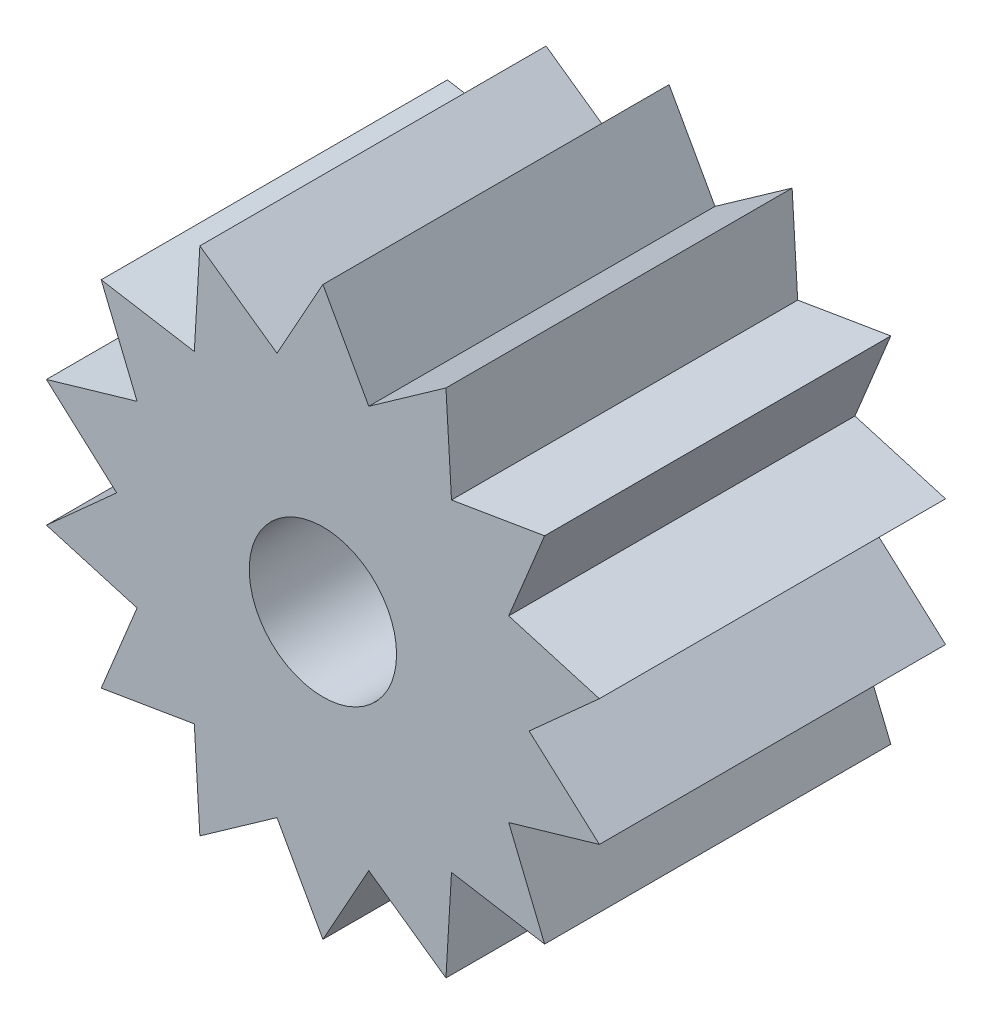
from build123d import *

# Parameters (mm, degrees)
SKETCH1_R           = 1
BOSS_EXTRUDE1_DEPTH = 4.7


with BuildPart() as part:
    # Sketch1 → Boss-Extrude1 (new body)
    with BuildSketch(Plane.XY):
        Polygon((0, 3.85), (0.623058615, 2.729798154), (1.670452396, 3.468730141), (1.745771445, 2.189128151), (3.010051208, 2.400435737), (2.52271283, 1.21487447), (3.753472462, 0.856705596), (2.8, 0), (3.753472462, -0.856705596), (2.52271283, -1.21487447), (3.010051208, -2.400435737), (1.745771445, -2.189128151), (1.670452396, -3.468730141), (0.623058615, -2.729798154), (0, -3.85), (-0.623058615, -2.729798154), (-1.670452396, -3.468730141), (-1.745771445, -2.189128151), (-3.010051208, -2.400435737), (-2.52271283, -1.21487447), (-3.753472462, -0.856705596), (-2.8, 0), (-3.753472462, 0.856705596), (-2.52271283, 1.21487447), (-3.010051208, 2.400435737), (-1.745771445, 2.189128151), (-1.670452396, 3.468730141), (-0.623058615, 2.729798154), align=None)
        Circle(SKETCH1_R, mode=Mode.SUBTRACT)
    extrude(amount=BOSS_EXTRUDE1_DEPTH)


solid = part.part
